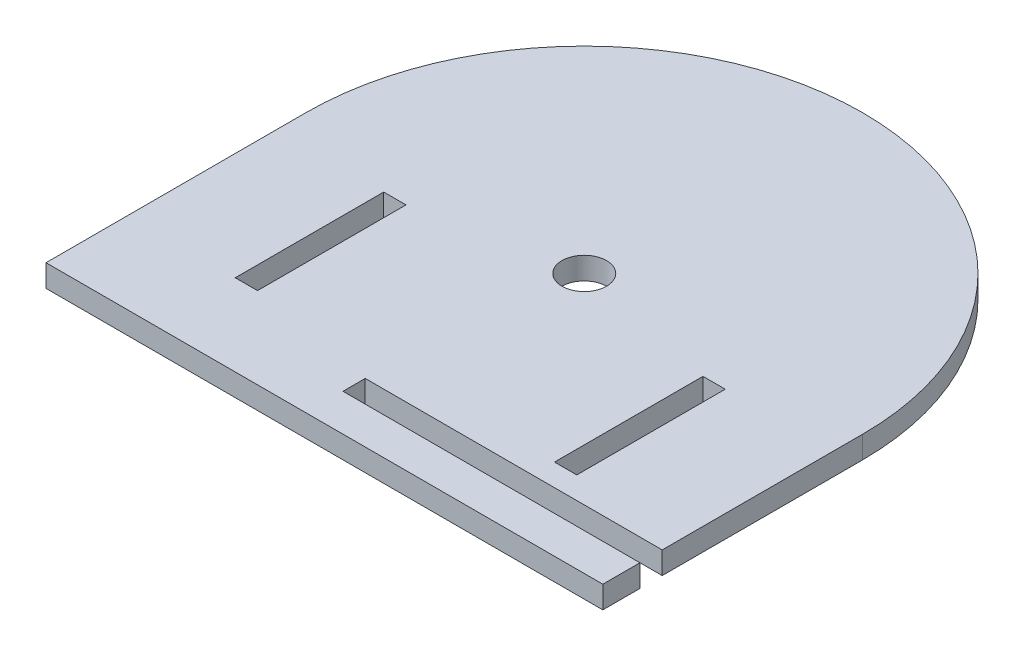
from build123d import *

# Parameters (mm, degrees)
SKETCH1_R           = 3
BOSS_EXTRUDE6_DEPTH = 3


with BuildPart() as part:
    # Sketch1 → Boss-Extrude6 (new body)
    with BuildSketch(Plane(origin=(0, 0, 0), x_dir=(1, 0, 0), z_dir=(0, 1, 0))):
        with BuildLine():
            ThreePointArc((70, 35), (107.5, 72.5), (145, 35))
            Line((145, 35), (145, 8))
            Line((145, 8), (105, 8))
            Line((105, 8), (105, 5))
            Line((105, 5), (145, 5))
            Line((145, 5), (145, 0))
            Line((145, 0), (70, 0))
            Line((70, 0), (70, 35))
        make_face()
        with Locations((107.5, 35)):
            Circle(SKETCH1_R, mode=Mode.SUBTRACT)
        Polygon((87.5, 10.989200562), (87.5, 20.989200562), (87.5, 30.989200562), (84.5, 30.989200562), (84.5, 10.989200562), align=None, mode=Mode.SUBTRACT)
        Polygon((130.5, 10.989200562), (127.5, 10.989200562), (127.5, 20.989200562), (127.5, 30.989200562), (130.5, 30.989200562), align=None, mode=Mode.SUBTRACT)
    extrude(amount=BOSS_EXTRUDE6_DEPTH)


solid = part.part
